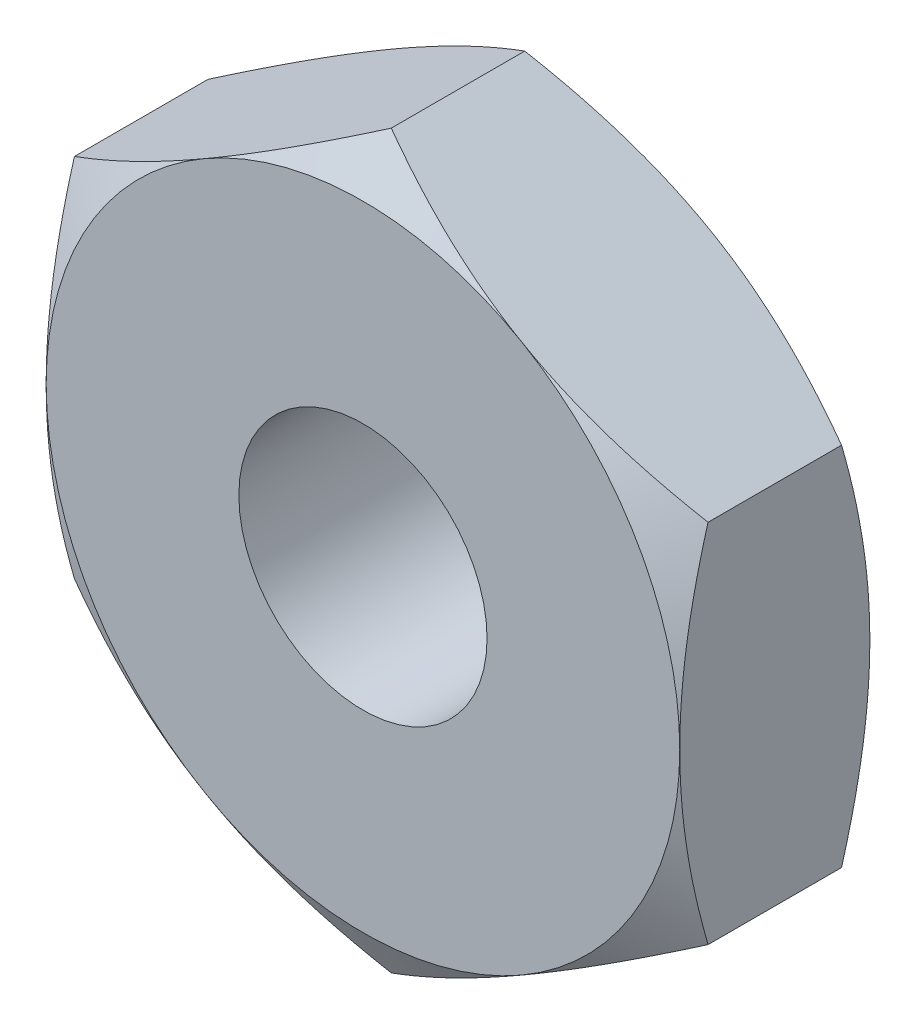
from build123d import *

# Parameters (mm, degrees)
SKETCH_1_R          = 0.7835
EXTRUDE_581_DEPTH   = 1.2
SKETCH_2_OUTSIDE_W  = 14.866
SKETCH_2_OUTSIDE_H  = 15.484
SKETCH_2_OUTSIDE_R  = 2
CUT_EXTRUDE_1_DEPTH = 2.2
CUT_EXTRUDE_1_TAPER = 60
SKETCH_3_OUTSIDE_W  = 14.866
SKETCH_3_OUTSIDE_H  = 15.484
SKETCH_3_OUTSIDE_R  = 2
CUT_EXTRUDE_2_DEPTH = 2.2
CUT_EXTRUDE_2_TAPER = 60


with BuildPart() as part:
    # 草图1 → Extrude 581 (new body)
    with BuildSketch(Plane.XY):
        Polygon((0, 2.309401077), (-2, 1.154700538), (-2, -1.154700538), (0, -2.309401077), (2, -1.154700538), (2, 1.154700538), align=None)
        Circle(SKETCH_1_R, mode=Mode.SUBTRACT)
    extrude(amount=EXTRUDE_581_DEPTH)

    # 草图2 outside → 切除-拉伸1 (cut, through all)
    with BuildSketch(Plane(origin=(0, 0, 0), x_dir=(-1, 0, 0), z_dir=(0, 0, -1))):
        Rectangle(SKETCH_2_OUTSIDE_W, SKETCH_2_OUTSIDE_H)
        Circle(SKETCH_2_OUTSIDE_R, mode=Mode.SUBTRACT)
    extrude(amount=-CUT_EXTRUDE_1_DEPTH, taper=CUT_EXTRUDE_1_TAPER, mode=Mode.SUBTRACT)

    # 草图3 outside → 切除-拉伸2 (cut, through all)
    with BuildSketch(Plane.XY.offset(1.2)):
        Rectangle(SKETCH_3_OUTSIDE_W, SKETCH_3_OUTSIDE_H)
        Circle(SKETCH_3_OUTSIDE_R, mode=Mode.SUBTRACT)
    extrude(amount=-CUT_EXTRUDE_2_DEPTH, taper=CUT_EXTRUDE_2_TAPER, mode=Mode.SUBTRACT)


solid = part.part
